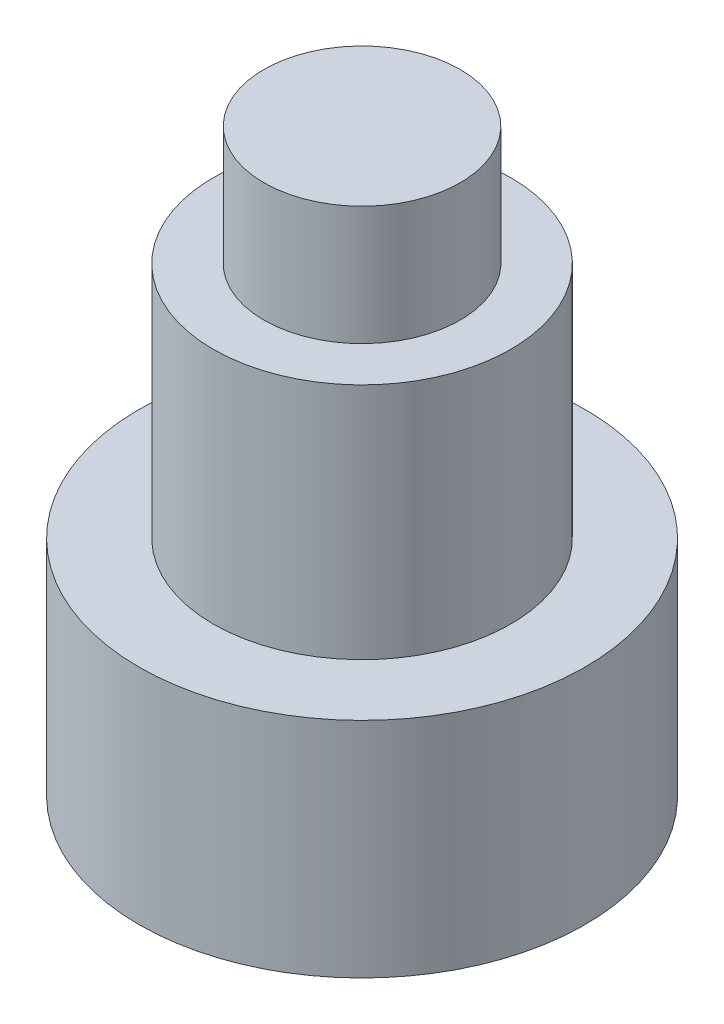
from build123d import *

# Parameters (mm, degrees)
SKETCH1_R           = 3.75
BOSS_EXTRUDE1_DEPTH = 7.75
SKETCH2_R           = 3.75
SKETCH2_R_2         = 2.5
CUT_EXTRUDE1_DEPTH  = 4
SKETCH3_R           = 1.65
BOSS_EXTRUDE2_DEPTH = 2


with BuildPart() as part:
    # Sketch1 → Boss-Extrude1 (new body)
    with BuildSketch(Plane(origin=(0, 0, 0), x_dir=(1, 0, 0), z_dir=(0, 1, 0))):
        Circle(SKETCH1_R)
    extrude(amount=BOSS_EXTRUDE1_DEPTH)

    # Sketch2 → Cut-Extrude1 (cut)
    with BuildSketch(Plane(origin=(0, 7.75, 0), x_dir=(1, 0, 0), z_dir=(0, 1, 0))):
        Circle(SKETCH2_R)
        Circle(SKETCH2_R_2, mode=Mode.SUBTRACT)
    extrude(amount=-CUT_EXTRUDE1_DEPTH, mode=Mode.SUBTRACT)

    # Sketch3 → Boss-Extrude2 (add)
    with BuildSketch(Plane(origin=(0, 7.75, 0), x_dir=(1, 0, 0), z_dir=(0, 1, 0))):
        Circle(SKETCH3_R)
    extrude(amount=BOSS_EXTRUDE2_DEPTH)


solid = part.part
